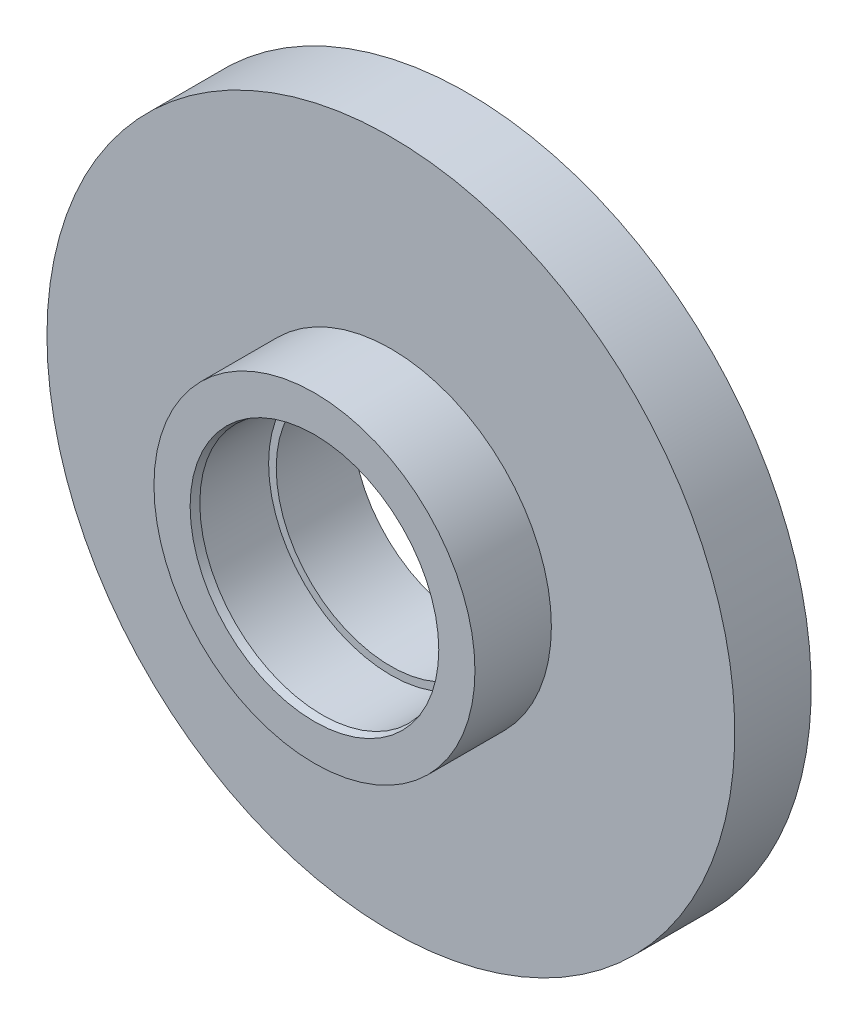
from build123d import *

# Parameters (mm, degrees)
CHAMFER1_SIZE  = 1
CHAMFER1_SIZE2 = 0.267949192


with BuildPart() as part:
    # Sketch1 → Revolve1 (revolve)
    with BuildSketch(Plane(origin=(0, 0, 0), x_dir=(1, 0, 0), z_dir=(0, 1, 0))):
        Polygon((16, 0), (16, 10), (15, 10), (15, 20), (45, 20), (45, 10), (21, 10), (21, 0), align=None)
    revolve(axis=Axis((0, 0, 0), (0, 0, 1)))

    # Chamfer1
    chamfer1_edges = [part.edges().sort_by_distance(p)[0] for p in [
        (-16, 0, 0),
    ]]
    chamfer1_side = [part.faces().sort_by_distance(p)[0] for p in [
        (-16, 0, -5),
    ]]
    chamfer(chamfer1_edges, length=CHAMFER1_SIZE, length2=CHAMFER1_SIZE2, reference=chamfer1_side[0])


solid = part.part
